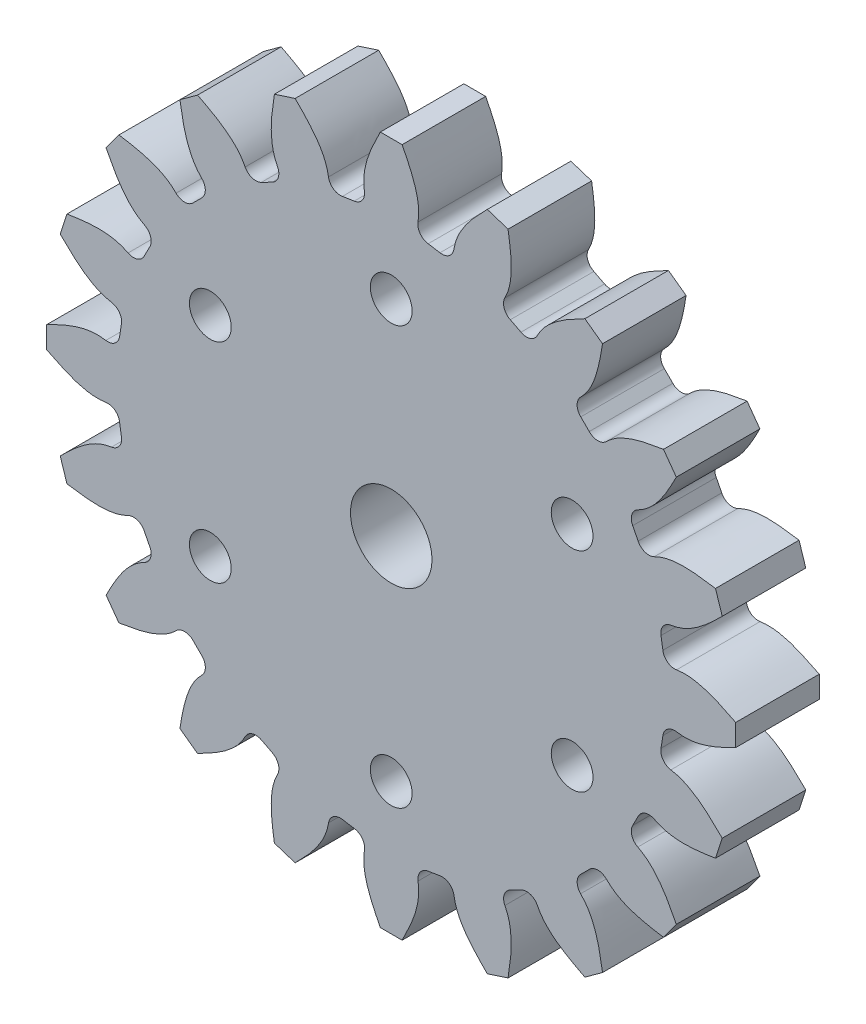
from build123d import *

# Parameters (mm, degrees)
EXTRUSION1_DEPTH = 6
ESQUISSE2_R      = 1.5
ESQUISSE2_R_2    = 2.925
EXTRUSION2_DEPTH = 7.0000001


with BuildPart() as part:
    # Esquisse1 → Extrusion1 (new body)
    with BuildSketch(Plane.XY):
        with BuildLine():
            Line((15.174347921, 19.552536029), (13.906435415, 20.473728387))
            add(Edge.make_bspline(
                [(13.906435415, 20.473728387), (13.161911087, 20.089071133), (12.003173391, 19.490411232), (10.90112508, 18.43010924), (10.569114946, 17.874191877), (10.482793627, 17.705958169)],
                knots=[0, 0, 0, 0, 0.322455921, 0.501853085, 0.575753282, 0.575753282, 0.575753282, 0.575753282], degree=3))
            ThreePointArc((10.482793627, 17.705958169), (9.976277871, 17.279938726), (9.317443872, 17.343093609))
            Line((9.317443872, 17.343093609), (8.550310802, 17.733861436))
            ThreePointArc((8.550310802, 17.733861436), (8.110634139, 18.233283909), (8.162134644, 18.896673742))
            add(Edge.make_bspline(
                [(8.162134644, 18.896673742), (8.247797428, 19.062368945), (8.505426142, 19.652428513), (8.711265683, 21.168177339), (8.515428147, 22.456750567), (8.389596554, 23.284698187)],
                knots=[0.425084378, 0.425084378, 0.425084378, 0.425084378, 0.498146915, 0.677544079, 1, 1, 1, 1], degree=3))
            Line((8.389596554, 23.284698187), (6.89907601, 23.768997669))
            add(Edge.make_bspline(
                [(6.89907601, 23.768997669), (6.309856925, 23.173096211), (5.392827972, 22.245667171), (4.672369079, 20.896708396), (4.52839659, 20.265402792), (4.498287212, 20.078728273)],
                knots=[0, 0, 0, 0, 0.322455921, 0.501853085, 0.575753282, 0.575753282, 0.575753282, 0.575753282], degree=3))
            ThreePointArc((4.498287212, 20.078728273), (4.148209349, 19.51703773), (3.50210505, 19.37351069))
            Line((3.50210505, 19.37351069), (2.651764245, 19.508095823))
            ThreePointArc((2.651764245, 19.508095823), (2.079276858, 19.847207259), (1.923258017, 20.494043014))
            add(Edge.make_bspline(
                [(1.923258017, 20.494043014), (1.953525532, 20.678099773), (2.016206565, 21.318891421), (1.743579456, 22.824062135), (1.159135865, 23.989050974), (0.783613024, 24.737591852)],
                knots=[0.425084378, 0.425084378, 0.425084378, 0.425084378, 0.498146915, 0.677544079, 1, 1, 1, 1], degree=3))
            Line((0.783613024, 24.737591852), (-0.783613024, 24.737591852))
            add(Edge.make_bspline(
                [(-0.783613024, 24.737591852), (-1.159849996, 23.988777176), (-1.745405023, 22.823362214), (-2.013750962, 21.317792138), (-1.955592776, 20.672894884), (-1.926542897, 20.486052557)],
                knots=[0, 0, 0, 0, 0.322455921, 0.501853085, 0.575753282, 0.575753282, 0.575753282, 0.575753282], degree=3))
            ThreePointArc((-1.926542897, 20.486052557), (-2.085914806, 19.843673097), (-2.656044216, 19.507513562))
            Line((-2.656044216, 19.507513562), (-3.506355473, 19.37274187))
            ThreePointArc((-3.506355473, 19.37274187), (-4.155614529, 19.518347679), (-4.503880505, 20.085312566))
            add(Edge.make_bspline(
                [(-4.503880505, 20.085312566), (-4.531971054, 20.269714122), (-4.670373358, 20.898512699), (-5.394780478, 22.245768705), (-6.310620712, 23.173135929), (-6.89907601, 23.768997669)],
                knots=[0.425084378, 0.425084378, 0.425084378, 0.425084378, 0.498146915, 0.677544079, 1, 1, 1, 1], degree=3))
            Line((-6.89907601, 23.768997669), (-8.389596554, 23.284698187))
            add(Edge.make_bspline(
                [(-8.389596554, 23.284698187), (-8.516022719, 22.456269491), (-8.712785614, 21.166947543), (-8.502751028, 19.652141856), (-8.248155095, 19.056779989), (-8.162789564, 18.888059282)],
                knots=[0, 0, 0, 0, 0.322455921, 0.501853085, 0.575753282, 0.575753282, 0.575753282, 0.575753282], degree=3))
            ThreePointArc((-8.162789564, 18.888059282), (-8.115855086, 18.227871482), (-8.554201368, 17.731985089))
            Line((-8.554201368, 17.731985089), (-9.321248686, 17.341048964))
            ThreePointArc((-9.321248686, 17.341048964), (-9.983725412, 17.278896236), (-10.490147823, 17.710491781))
            add(Edge.make_bspline(
                [(-10.490147823, 17.710491781), (-10.573846737, 17.877187625), (-10.899784597, 18.432441945), (-12.00506171, 19.489904438), (-13.162649765, 20.088872883), (-13.906435415, 20.473728387)],
                knots=[0.425084378, 0.425084378, 0.425084378, 0.425084378, 0.498146915, 0.677544079, 1, 1, 1, 1], degree=3))
            Line((-13.906435415, 20.473728387), (-15.174347921, 19.552536029))
            add(Edge.make_bspline(
                [(-15.174347921, 19.552536029), (-15.038587803, 18.725585687), (-14.827298043, 17.438564568), (-14.159442581, 16.062803005), (-13.733330525, 15.575254691), (-13.600005515, 15.441171164)],
                knots=[0, 0, 0, 0, 0.322455921, 0.501853085, 0.575753282, 0.575753282, 0.575753282, 0.575753282], degree=3))
            ThreePointArc((-13.600005515, 15.441171164), (-13.351358924, 14.827798806), (-13.615013689, 14.22072637))
            Line((-13.615013689, 14.22072637), (-14.223713133, 13.611893364))
            ThreePointArc((-14.223713133, 13.611893364), (-14.834559691, 13.34806604), (-15.449566383, 13.602044664))
            add(Edge.make_bspline(
                [(-15.449566383, 13.602044664), (-15.58068063, 13.734717446), (-16.062248976, 14.162075348), (-17.440203858, 14.826232531), (-18.72622695, 15.038170992), (-19.552536029, 15.174347921)],
                knots=[0.425084378, 0.425084378, 0.425084378, 0.425084378, 0.498146915, 0.677544079, 1, 1, 1, 1], degree=3))
            Line((-19.552536029, 15.174347921), (-20.473728387, 13.906435415))
            add(Edge.make_bspline(
                [(-20.473728387, 13.906435415), (-20.089071133, 13.161911087), (-19.490411232, 12.003173391), (-18.43010924, 10.90112508), (-17.874191877, 10.569114946), (-17.705958169, 10.482793627)],
                knots=[0, 0, 0, 0, 0.322455921, 0.501853085, 0.575753282, 0.575753282, 0.575753282, 0.575753282], degree=3))
            ThreePointArc((-17.705958169, 10.482793627), (-17.279938726, 9.976277871), (-17.343093609, 9.317443872))
            Line((-17.343093609, 9.317443872), (-17.733861436, 8.550310802))
            ThreePointArc((-17.733861436, 8.550310802), (-18.233283909, 8.110634139), (-18.896673742, 8.162134644))
            add(Edge.make_bspline(
                [(-18.896673742, 8.162134644), (-19.062368945, 8.247797428), (-19.652428513, 8.505426142), (-21.168177339, 8.711265683), (-22.456750567, 8.515428147), (-23.284698187, 8.389596554)],
                knots=[0.425084378, 0.425084378, 0.425084378, 0.425084378, 0.498146915, 0.677544079, 1, 1, 1, 1], degree=3))
            Line((-23.284698187, 8.389596554), (-23.768997669, 6.89907601))
            add(Edge.make_bspline(
                [(-23.768997669, 6.89907601), (-23.173096211, 6.309856925), (-22.245667171, 5.392827972), (-20.896708396, 4.672369079), (-20.265402792, 4.52839659), (-20.078728273, 4.498287212)],
                knots=[0, 0, 0, 0, 0.322455921, 0.501853085, 0.575753282, 0.575753282, 0.575753282, 0.575753282], degree=3))
            ThreePointArc((-20.078728273, 4.498287212), (-19.51703773, 4.148209349), (-19.37351069, 3.50210505))
            Line((-19.37351069, 3.50210505), (-19.508095823, 2.651764245))
            ThreePointArc((-19.508095823, 2.651764245), (-19.847207259, 2.079276858), (-20.494043014, 1.923258017))
            add(Edge.make_bspline(
                [(-20.494043014, 1.923258017), (-20.678099773, 1.953525532), (-21.318891421, 2.016206565), (-22.824062135, 1.743579456), (-23.989050974, 1.159135865), (-24.737591852, 0.783613024)],
                knots=[0.425084378, 0.425084378, 0.425084378, 0.425084378, 0.498146915, 0.677544079, 1, 1, 1, 1], degree=3))
            Line((-24.737591852, 0.783613024), (-24.737591852, -0.783613024))
            add(Edge.make_bspline(
                [(-24.737591852, -0.783613024), (-23.988777176, -1.159849996), (-22.823362214, -1.745405023), (-21.317792138, -2.013750962), (-20.672894884, -1.955592776), (-20.486052557, -1.926542897)],
                knots=[0, 0, 0, 0, 0.322455921, 0.501853085, 0.575753282, 0.575753282, 0.575753282, 0.575753282], degree=3))
            ThreePointArc((-20.486052557, -1.926542897), (-19.843673097, -2.085914806), (-19.507513562, -2.656044216))
            Line((-19.507513562, -2.656044216), (-19.37274187, -3.506355473))
            ThreePointArc((-19.37274187, -3.506355473), (-19.518347679, -4.155614529), (-20.085312566, -4.503880505))
            add(Edge.make_bspline(
                [(-20.085312566, -4.503880505), (-20.269714122, -4.531971054), (-20.898512699, -4.670373358), (-22.245768705, -5.394780478), (-23.173135929, -6.310620712), (-23.768997669, -6.89907601)],
                knots=[0.425084378, 0.425084378, 0.425084378, 0.425084378, 0.498146915, 0.677544079, 1, 1, 1, 1], degree=3))
            Line((-23.768997669, -6.89907601), (-23.284698187, -8.389596554))
            add(Edge.make_bspline(
                [(-23.284698187, -8.389596554), (-22.456269491, -8.516022719), (-21.166947543, -8.712785614), (-19.652141856, -8.502751028), (-19.056779989, -8.248155095), (-18.888059282, -8.162789564)],
                knots=[0, 0, 0, 0, 0.322455921, 0.501853085, 0.575753282, 0.575753282, 0.575753282, 0.575753282], degree=3))
            ThreePointArc((-18.888059282, -8.162789564), (-18.227871482, -8.115855086), (-17.731985089, -8.554201368))
            Line((-17.731985089, -8.554201368), (-17.341048964, -9.321248686))
            ThreePointArc((-17.341048964, -9.321248686), (-17.278896236, -9.983725412), (-17.710491781, -10.490147823))
            add(Edge.make_bspline(
                [(-17.710491781, -10.490147823), (-17.877187625, -10.573846737), (-18.432441945, -10.899784597), (-19.489904438, -12.00506171), (-20.088872883, -13.162649765), (-20.473728387, -13.906435415)],
                knots=[0.425084378, 0.425084378, 0.425084378, 0.425084378, 0.498146915, 0.677544079, 1, 1, 1, 1], degree=3))
            Line((-20.473728387, -13.906435415), (-19.552536029, -15.174347921))
            add(Edge.make_bspline(
                [(-19.552536029, -15.174347921), (-18.725585687, -15.038587803), (-17.438564568, -14.827298043), (-16.062803005, -14.159442581), (-15.575254691, -13.733330525), (-15.441171164, -13.600005515)],
                knots=[0, 0, 0, 0, 0.322455921, 0.501853085, 0.575753282, 0.575753282, 0.575753282, 0.575753282], degree=3))
            ThreePointArc((-15.441171164, -13.600005515), (-14.827798806, -13.351358924), (-14.22072637, -13.615013689))
            Line((-14.22072637, -13.615013689), (-13.611893364, -14.223713133))
            ThreePointArc((-13.611893364, -14.223713133), (-13.34806604, -14.834559691), (-13.602044664, -15.449566383))
            add(Edge.make_bspline(
                [(-13.602044664, -15.449566383), (-13.734717446, -15.58068063), (-14.162075348, -16.062248976), (-14.826232531, -17.440203858), (-15.038170992, -18.72622695), (-15.174347921, -19.552536029)],
                knots=[0.425084378, 0.425084378, 0.425084378, 0.425084378, 0.498146915, 0.677544079, 1, 1, 1, 1], degree=3))
            Line((-15.174347921, -19.552536029), (-13.906435415, -20.473728387))
            add(Edge.make_bspline(
                [(-13.906435415, -20.473728387), (-13.161911087, -20.089071133), (-12.003173391, -19.490411232), (-10.90112508, -18.43010924), (-10.569114946, -17.874191877), (-10.482793627, -17.705958169)],
                knots=[0, 0, 0, 0, 0.322455921, 0.501853085, 0.575753282, 0.575753282, 0.575753282, 0.575753282], degree=3))
            ThreePointArc((-10.482793627, -17.705958169), (-9.976277871, -17.279938726), (-9.317443872, -17.343093609))
            Line((-9.317443872, -17.343093609), (-8.550310802, -17.733861436))
            ThreePointArc((-8.550310802, -17.733861436), (-8.110634139, -18.233283909), (-8.162134644, -18.896673742))
            add(Edge.make_bspline(
                [(-8.162134644, -18.896673742), (-8.247797428, -19.062368945), (-8.505426142, -19.652428513), (-8.711265683, -21.168177339), (-8.515428147, -22.456750567), (-8.389596554, -23.284698187)],
                knots=[0.425084378, 0.425084378, 0.425084378, 0.425084378, 0.498146915, 0.677544079, 1, 1, 1, 1], degree=3))
            Line((-8.389596554, -23.284698187), (-6.89907601, -23.768997669))
            add(Edge.make_bspline(
                [(-6.89907601, -23.768997669), (-6.309856925, -23.173096211), (-5.392827972, -22.245667171), (-4.672369079, -20.896708396), (-4.52839659, -20.265402792), (-4.498287212, -20.078728273)],
                knots=[0, 0, 0, 0, 0.322455921, 0.501853085, 0.575753282, 0.575753282, 0.575753282, 0.575753282], degree=3))
            ThreePointArc((-4.498287212, -20.078728273), (-4.148209349, -19.51703773), (-3.50210505, -19.37351069))
            Line((-3.50210505, -19.37351069), (-2.651764245, -19.508095823))
            ThreePointArc((-2.651764245, -19.508095823), (-2.079276858, -19.847207259), (-1.923258017, -20.494043014))
            add(Edge.make_bspline(
                [(-1.923258017, -20.494043014), (-1.953525532, -20.678099773), (-2.016206565, -21.318891421), (-1.743579456, -22.824062135), (-1.159135865, -23.989050974), (-0.783613024, -24.737591852)],
                knots=[0.425084378, 0.425084378, 0.425084378, 0.425084378, 0.498146915, 0.677544079, 1, 1, 1, 1], degree=3))
            Line((-0.783613024, -24.737591852), (0.783613024, -24.737591852))
            add(Edge.make_bspline(
                [(0.783613024, -24.737591852), (1.159849996, -23.988777176), (1.745405023, -22.823362214), (2.013750962, -21.317792138), (1.955592776, -20.672894884), (1.926542897, -20.486052557)],
                knots=[0, 0, 0, 0, 0.322455921, 0.501853085, 0.575753282, 0.575753282, 0.575753282, 0.575753282], degree=3))
            ThreePointArc((1.926542897, -20.486052557), (2.085914806, -19.843673097), (2.656044216, -19.507513562))
            Line((2.656044216, -19.507513562), (3.506355473, -19.37274187))
            ThreePointArc((3.506355473, -19.37274187), (4.155614529, -19.518347679), (4.503880505, -20.085312566))
            add(Edge.make_bspline(
                [(4.503880505, -20.085312566), (4.531971054, -20.269714122), (4.670373358, -20.898512699), (5.394780478, -22.245768705), (6.310620712, -23.173135929), (6.89907601, -23.768997669)],
                knots=[0.425084378, 0.425084378, 0.425084378, 0.425084378, 0.498146915, 0.677544079, 1, 1, 1, 1], degree=3))
            Line((6.89907601, -23.768997669), (8.389596554, -23.284698187))
            add(Edge.make_bspline(
                [(8.389596554, -23.284698187), (8.516022719, -22.456269491), (8.712785614, -21.166947543), (8.502751028, -19.652141856), (8.248155095, -19.056779989), (8.162789564, -18.888059282)],
                knots=[0, 0, 0, 0, 0.322455921, 0.501853085, 0.575753282, 0.575753282, 0.575753282, 0.575753282], degree=3))
            ThreePointArc((8.162789564, -18.888059282), (8.115855086, -18.227871482), (8.554201368, -17.731985089))
            Line((8.554201368, -17.731985089), (9.321248686, -17.341048964))
            ThreePointArc((9.321248686, -17.341048964), (9.983725412, -17.278896236), (10.490147823, -17.710491781))
            add(Edge.make_bspline(
                [(10.490147823, -17.710491781), (10.573846737, -17.877187625), (10.899784597, -18.432441945), (12.00506171, -19.489904438), (13.162649765, -20.088872883), (13.906435415, -20.473728387)],
                knots=[0.425084378, 0.425084378, 0.425084378, 0.425084378, 0.498146915, 0.677544079, 1, 1, 1, 1], degree=3))
            Line((13.906435415, -20.473728387), (15.174347921, -19.552536029))
            add(Edge.make_bspline(
                [(15.174347921, -19.552536029), (15.038587803, -18.725585687), (14.827298043, -17.438564568), (14.159442581, -16.062803005), (13.733330525, -15.575254691), (13.600005515, -15.441171164)],
                knots=[0, 0, 0, 0, 0.322455921, 0.501853085, 0.575753282, 0.575753282, 0.575753282, 0.575753282], degree=3))
            ThreePointArc((13.600005515, -15.441171164), (13.351358924, -14.827798806), (13.615013689, -14.22072637))
            Line((13.615013689, -14.22072637), (14.223713133, -13.611893364))
            ThreePointArc((14.223713133, -13.611893364), (14.834559691, -13.34806604), (15.449566383, -13.602044664))
            add(Edge.make_bspline(
                [(15.449566383, -13.602044664), (15.58068063, -13.734717446), (16.062248976, -14.162075348), (17.440203858, -14.826232531), (18.72622695, -15.038170992), (19.552536029, -15.174347921)],
                knots=[0.425084378, 0.425084378, 0.425084378, 0.425084378, 0.498146915, 0.677544079, 1, 1, 1, 1], degree=3))
            Line((19.552536029, -15.174347921), (20.473728387, -13.906435415))
            add(Edge.make_bspline(
                [(20.473728387, -13.906435415), (20.089071133, -13.161911087), (19.490411232, -12.003173391), (18.43010924, -10.90112508), (17.874191877, -10.569114946), (17.705958169, -10.482793627)],
                knots=[0, 0, 0, 0, 0.322455921, 0.501853085, 0.575753282, 0.575753282, 0.575753282, 0.575753282], degree=3))
            ThreePointArc((17.705958169, -10.482793627), (17.279938726, -9.976277871), (17.343093609, -9.317443872))
            Line((17.343093609, -9.317443872), (17.733861436, -8.550310802))
            ThreePointArc((17.733861436, -8.550310802), (18.233283909, -8.110634139), (18.896673742, -8.162134644))
            add(Edge.make_bspline(
                [(18.896673742, -8.162134644), (19.062368945, -8.247797428), (19.652428513, -8.505426142), (21.168177339, -8.711265683), (22.456750567, -8.515428147), (23.284698187, -8.389596554)],
                knots=[0.425084378, 0.425084378, 0.425084378, 0.425084378, 0.498146915, 0.677544079, 1, 1, 1, 1], degree=3))
            Line((23.284698187, -8.389596554), (23.768997669, -6.89907601))
            add(Edge.make_bspline(
                [(23.768997669, -6.89907601), (23.173096211, -6.309856925), (22.245667171, -5.392827972), (20.896708396, -4.672369079), (20.265402792, -4.52839659), (20.078728273, -4.498287212)],
                knots=[0, 0, 0, 0, 0.322455921, 0.501853085, 0.575753282, 0.575753282, 0.575753282, 0.575753282], degree=3))
            ThreePointArc((20.078728273, -4.498287212), (19.51703773, -4.148209349), (19.37351069, -3.50210505))
            Line((19.37351069, -3.50210505), (19.508095823, -2.651764245))
            ThreePointArc((19.508095823, -2.651764245), (19.847207259, -2.079276858), (20.494043014, -1.923258017))
            add(Edge.make_bspline(
                [(20.494043014, -1.923258017), (20.678099773, -1.953525532), (21.318891421, -2.016206565), (22.824062135, -1.743579456), (23.989050974, -1.159135865), (24.737591852, -0.783613024)],
                knots=[0.425084378, 0.425084378, 0.425084378, 0.425084378, 0.498146915, 0.677544079, 1, 1, 1, 1], degree=3))
            Line((24.737591852, -0.783613024), (24.737591852, 0.783613024))
            add(Edge.make_bspline(
                [(24.737591852, 0.783613024), (23.988777176, 1.159849996), (22.823362214, 1.745405023), (21.317792138, 2.013750962), (20.672894884, 1.955592776), (20.486052557, 1.926542897)],
                knots=[0, 0, 0, 0, 0.322455921, 0.501853085, 0.575753282, 0.575753282, 0.575753282, 0.575753282], degree=3))
            ThreePointArc((20.486052557, 1.926542897), (19.843673097, 2.085914806), (19.507513562, 2.656044216))
            Line((19.507513562, 2.656044216), (19.37274187, 3.506355473))
            ThreePointArc((19.37274187, 3.506355473), (19.518347679, 4.155614529), (20.085312566, 4.503880505))
            add(Edge.make_bspline(
                [(20.085312566, 4.503880505), (20.269714122, 4.531971054), (20.898512699, 4.670373358), (22.245768705, 5.394780478), (23.173135929, 6.310620712), (23.768997669, 6.89907601)],
                knots=[0.425084378, 0.425084378, 0.425084378, 0.425084378, 0.498146915, 0.677544079, 1, 1, 1, 1], degree=3))
            Line((23.768997669, 6.89907601), (23.284698187, 8.389596554))
            add(Edge.make_bspline(
                [(23.284698187, 8.389596554), (22.456269491, 8.516022719), (21.166947543, 8.712785614), (19.652141856, 8.502751028), (19.056779989, 8.248155095), (18.888059282, 8.162789564)],
                knots=[0, 0, 0, 0, 0.322455921, 0.501853085, 0.575753282, 0.575753282, 0.575753282, 0.575753282], degree=3))
            ThreePointArc((18.888059282, 8.162789564), (18.227871482, 8.115855086), (17.731985089, 8.554201368))
            Line((17.731985089, 8.554201368), (17.341048964, 9.321248686))
            ThreePointArc((17.341048964, 9.321248686), (17.278896236, 9.983725412), (17.710491781, 10.490147823))
            add(Edge.make_bspline(
                [(17.710491781, 10.490147823), (17.877187625, 10.573846737), (18.432441945, 10.899784597), (19.489904438, 12.00506171), (20.088872883, 13.162649765), (20.473728387, 13.906435415)],
                knots=[0.425084378, 0.425084378, 0.425084378, 0.425084378, 0.498146915, 0.677544079, 1, 1, 1, 1], degree=3))
            Line((20.473728387, 13.906435415), (19.552536029, 15.174347921))
            add(Edge.make_bspline(
                [(19.552536029, 15.174347921), (18.725585687, 15.038587803), (17.438564568, 14.827298043), (16.062803005, 14.159442581), (15.575254691, 13.733330525), (15.441171164, 13.600005515)],
                knots=[0, 0, 0, 0, 0.322455921, 0.501853085, 0.575753282, 0.575753282, 0.575753282, 0.575753282], degree=3))
            ThreePointArc((15.441171164, 13.600005515), (14.827798806, 13.351358924), (14.22072637, 13.615013689))
            Line((14.22072637, 13.615013689), (13.611893364, 14.223713133))
            ThreePointArc((13.611893364, 14.223713133), (13.34806604, 14.834559691), (13.602044664, 15.449566383))
            add(Edge.make_bspline(
                [(13.602044664, 15.449566383), (13.734717446, 15.58068063), (14.162075348, 16.062248976), (14.826232531, 17.440203858), (15.038170992, 18.72622695), (15.174347921, 19.552536029)],
                knots=[0.425084378, 0.425084378, 0.425084378, 0.425084378, 0.498146915, 0.677544079, 1, 1, 1, 1], degree=3))
        make_face()
    extrude(amount=EXTRUSION1_DEPTH)

    # Esquisse2 → Extrusion2 (cut, through all)
    with BuildSketch(Plane(origin=(0, 0, 0), x_dir=(-1, 0, 0), z_dir=(0, 0, -1))):
        with Locations((0, 14.744290133)):
            Circle(ESQUISSE2_R)
        with Locations((12.990381057, 7.244290133)):
            Circle(ESQUISSE2_R)
        with Locations((12.990381057, -7.755709867)):
            Circle(ESQUISSE2_R)
        with Locations((0, -15.255709867)):
            Circle(ESQUISSE2_R)
        with Locations((-12.990381057, -7.755709867)):
            Circle(ESQUISSE2_R)
        with Locations((-12.990381057, 7.244290133)):
            Circle(ESQUISSE2_R)
        Circle(ESQUISSE2_R_2)
    extrude(amount=-EXTRUSION2_DEPTH, mode=Mode.SUBTRACT)


solid = part.part
